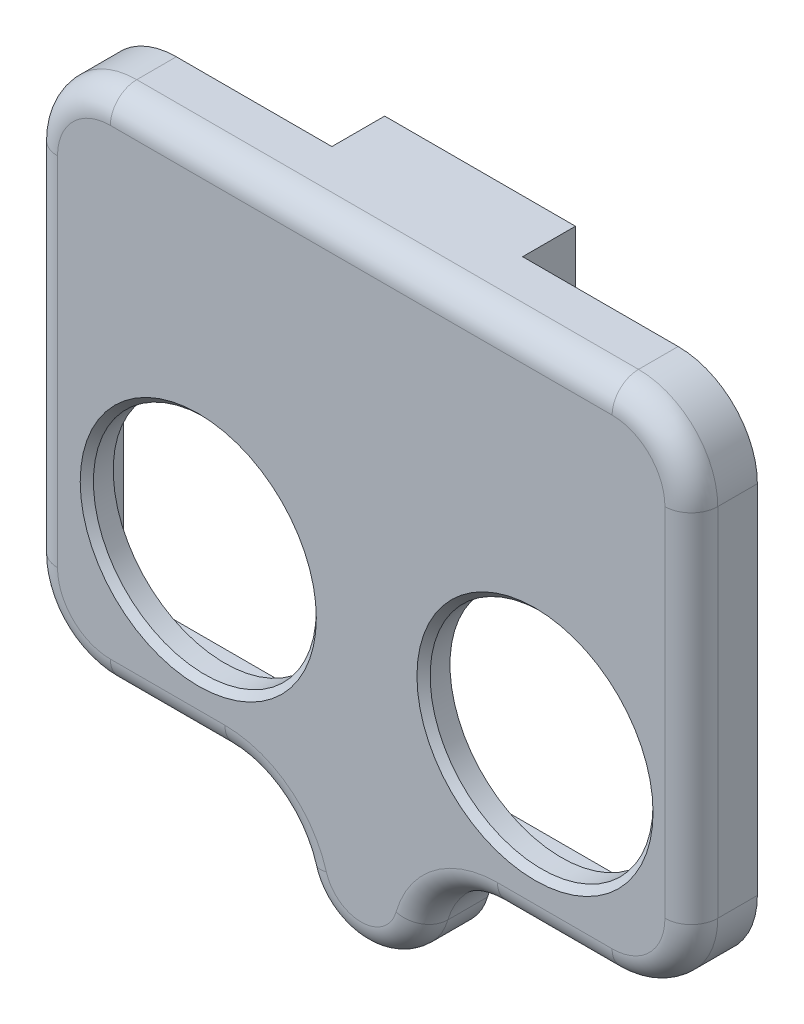
from build123d import *

# Parameters (mm, degrees)
SKETCH1_W           = 46
SKETCH1_H           = 21
SKETCH1_R           = 1.5
BOSS_EXTRUDE1_DEPTH = 3
BOSS_EXTRUDE2_DEPTH = 4
SKETCH5_R           = 8.44
BOSS_EXTRUDE3_DEPTH = 2
FILLET3_R           = 2
CHAMFER1_SIZE       = 0.5


with BuildPart() as part:
    # Sketch1 → Boss-Extrude1 (new body)
    with BuildSketch(Plane.XY):
        with BuildLine():
            Line((19, 0), (-19, 0))
            ThreePointArc((-19, 0), (-23.242640687, -1.757359313), (-25, -6))
            Line((-25, -6), (-25, -33))
            ThreePointArc((-25, -33), (-23.242640687, -37.242640687), (-19, -39))
            Line((-19, -39), (-10.322911411, -39))
            ThreePointArc((-10.322911411, -39), (-6.72058658, -40.201744503), (-4.561286437, -43.325581395))
            ThreePointArc((-4.561286437, -43.325581395), (0, -46.75), (4.561286437, -43.325581395))
            ThreePointArc((4.561286437, -43.325581395), (6.72058658, -40.201744503), (10.322911411, -39))
            Line((10.322911411, -39), (19, -39))
            ThreePointArc((19, -39), (23.242640687, -37.242640687), (25, -33))
            Line((25, -33), (25, -6))
            ThreePointArc((25, -6), (23.242640687, -1.757359313), (19, 0))
        make_face()
        with Locations((0, -26.5)):
            Rectangle(SKETCH1_W, SKETCH1_H, mode=Mode.SUBTRACT)
        with Locations((0, -42)):
            Circle(SKETCH1_R, mode=Mode.SUBTRACT)
        with Locations((-20, -5)):
            Circle(SKETCH1_R, mode=Mode.SUBTRACT)
        with Locations((20, -5)):
            Circle(SKETCH1_R, mode=Mode.SUBTRACT)
    extrude(amount=BOSS_EXTRUDE1_DEPTH)

    # Sketch3 → Boss-Extrude2 (add)
    with BuildSketch(Plane(origin=(0, 0, 0), x_dir=(-1, 0, 0), z_dir=(0, 0, -1))):
        Polygon((-7.223, 0), (-7.223, -5.965393219), (-6.223, -6.965393219), (-6.223, -10.04450176), (6.223, -10.04450176), (6.223, -6.965393219), (7.223, -5.965393219), (7.223, 0), align=None)
    extrude(amount=BOSS_EXTRUDE2_DEPTH)

    # Sketch5 → Boss-Extrude3 (add)
    with BuildSketch(Plane.XY.offset(3)):
        with BuildLine():
            Line((19, 0), (-19, 0))
            ThreePointArc((-19, 0), (-23.242640687, -1.757359313), (-25, -6))
            Line((-25, -6), (-25, -33))
            ThreePointArc((-25, -33), (-23.242640687, -37.242640687), (-19, -39))
            Line((-19, -39), (-10.322911411, -39))
            ThreePointArc((-10.322911411, -39), (-6.72058658, -40.201744503), (-4.561286437, -43.325581395))
            ThreePointArc((-4.561286437, -43.325581395), (0, -46.75), (4.561286437, -43.325581395))
            ThreePointArc((4.561286437, -43.325581395), (6.72058658, -40.201744503), (10.322911411, -39))
            Line((10.322911411, -39), (19, -39))
            ThreePointArc((19, -39), (23.242640687, -37.242640687), (25, -33))
            Line((25, -33), (25, -6))
            ThreePointArc((25, -6), (23.242640687, -1.757359313), (19, 0))
        make_face()
        with Locations((13.16, -26.5)):
            Circle(SKETCH5_R, mode=Mode.SUBTRACT)
        with Locations((-12.34, -26.5)):
            Circle(SKETCH5_R, mode=Mode.SUBTRACT)
    extrude(amount=BOSS_EXTRUDE3_DEPTH)

    # Fillet3
    fillet3_edges = [part.edges().sort_by_distance(p)[0] for p in [
        (-6.72058658, -40.201744503, 5),
        (0, -46.75, 5),
        (6.72058658, -40.201744503, 5),
        (14.661455706, -39, 5),
        (23.242640687, -37.242640687, 5),
        (25, -19.5, 5),
        (23.242640687, -1.757359313, 5),
        (0, 0, 5),
        (-23.242640687, -1.757359313, 5),
        (-25, -19.5, 5),
        (-23.242640687, -37.242640687, 5),
        (-14.661455706, -39, 5),
    ]]
    fillet(fillet3_edges, radius=FILLET3_R)

    # Chamfer1
    chamfer1_edges = [part.edges().sort_by_distance(p)[0] for p in [
        (-20.78, -26.5, 5),
        (4.72, -26.5, 5),
    ]]
    chamfer(chamfer1_edges, length=CHAMFER1_SIZE)


solid = part.part
